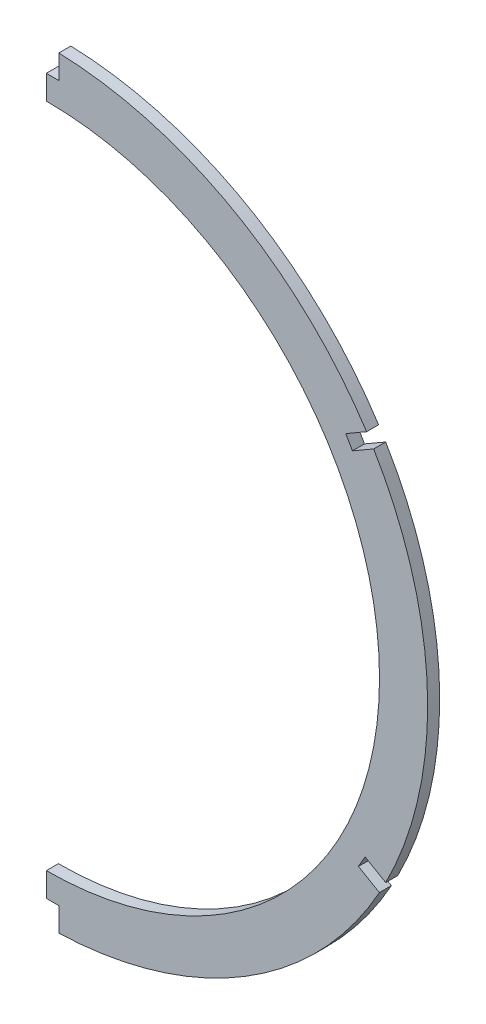
from build123d import *

# Parameters (mm, degrees)
BOSS_EXTRUDE1_DEPTH = 3.175
SKETCH3_W           = 149.303507008
SKETCH3_H           = 288.678903575
CUT_EXTRUDE1_DEPTH  = 101.601825753
CUT_EXTRUDE2_DEPTH  = 4.175


with BuildPart() as part:
    # Sketch2 → Boss-Extrude1 (new body)
    with BuildSketch(Plane.XY):
        with BuildLine():
            ThreePointArc((-1.783927604, 106.664181958), (-86.289926541, 57.796410124), (-89.548347912, -39.767444199))
            ThreePointArc((-89.548347912, -39.767444199), (-89.139366423, -40.557656379), (-88.723411943, -41.344220438))
            ThreePointArc((-88.723411943, -41.344220438), (-88.300763494, -42.126623343), (-87.87121564, -42.905259753))
            ThreePointArc((-87.87121564, -42.905259753), (0, -94.523651503), (87.87121564, -42.905259753))
            ThreePointArc((87.87121564, -42.905259753), (88.300763494, -42.126623343), (88.723411943, -41.344220438))
            ThreePointArc((88.723411943, -41.344220438), (89.139366423, -40.557656379), (89.548347912, -39.767444199))
            ThreePointArc((89.548347912, -39.767444199), (86.289926541, 57.796410124), (1.783927604, 106.664181958))
            ThreePointArc((1.783927604, 106.664181958), (0.891998866, 106.676045412), (0, 106.68))
            ThreePointArc((0, 106.68), (-0.891998866, 106.676045412), (-1.783927604, 106.664181958))
        make_face()
        with BuildLine():
            ThreePointArc((-7.652045127, 93.646303016), (0, -81.823651503), (7.652045127, 93.646303016))
            ThreePointArc((7.652045127, 93.646303016), (4.717664566, 93.853310885), (1.778000524, 93.962016248))
            ThreePointArc((1.778000524, 93.962016248), (0.889045735, 93.975503947), (0, 93.98))
            ThreePointArc((0, 93.98), (-0.889045735, 93.975503947), (-1.778000524, 93.962016248))
            ThreePointArc((-1.778000524, 93.962016248), (-4.717664566, 93.853310885), (-7.652045127, 93.646303016))
        make_face(mode=Mode.SUBTRACT)
    extrude(amount=-BOSS_EXTRUDE1_DEPTH)

    # Sketch3 → Cut-Extrude1 (cut, through all)
    with BuildSketch(Plane(origin=(0, 0, 0), x_dir=(0, 0, -1), z_dir=(1, 0, 0))):
        with Locations((2.160275602, 8.369276658)):
            Rectangle(SKETCH3_W, SKETCH3_H)
    extrude(amount=-CUT_EXTRUDE1_DEPTH, mode=Mode.SUBTRACT)

    # Sketch4 → Cut-Extrude2 (cut, through all)
    with BuildSketch(Plane.XY):
        with BuildLine():
            ThreePointArc((0, 106.68), (1.651222436, 106.666447964), (3.302, 106.625795506))
            Line((3.302, 106.625795506), (3.302, 110.295839279))
            Line((3.302, 110.295839279), (0, 110.295839279))
            Line((0, 110.295839279), (0, 106.68))
        make_face()
        with BuildLine():
            Line((3.302, 100.33), (3.302, 106.625795506))
            ThreePointArc((3.302, 106.625795506), (1.651222436, 106.666447964), (0, 106.68))
            Line((0, 106.68), (0, 100.33))
            Line((0, 100.33), (3.302, 100.33))
        make_face()
        with BuildLine():
            Line((82.32974483, -39.7035932), (87.872184265, -42.9035221))
            ThreePointArc((87.872184265, -42.9035221), (88.718599471, -41.35322308), (89.537666015, -39.788302716))
            Line((89.537666015, -39.788302716), (84.09504483, -36.64600391))
            Line((84.09504483, -36.64600391), (82.32974483, -39.7035932))
        make_face()
        with BuildLine():
            Line((3.302, -94.469447009), (3.302, -88.173651503))
            Line((3.302, -88.173651503), (0, -88.173651503))
            Line((0, -88.173651503), (0, -94.523651503))
            ThreePointArc((0, -94.523651503), (1.651222436, -94.510099467), (3.302, -94.469447009))
        make_face()
        with BuildLine():
            Line((80.761862371, 54.45739012), (86.35548549, 57.686869933))
            ThreePointArc((86.35548549, 57.686869933), (85.436094759, 59.195036514), (84.490367241, 60.686829131))
            Line((84.490367241, 60.686829131), (78.996562371, 57.51497941))
            Line((78.996562371, 57.51497941), (80.761862371, 54.45739012))
        make_face()
    extrude(amount=-CUT_EXTRUDE2_DEPTH, mode=Mode.SUBTRACT)


solid = part.part
